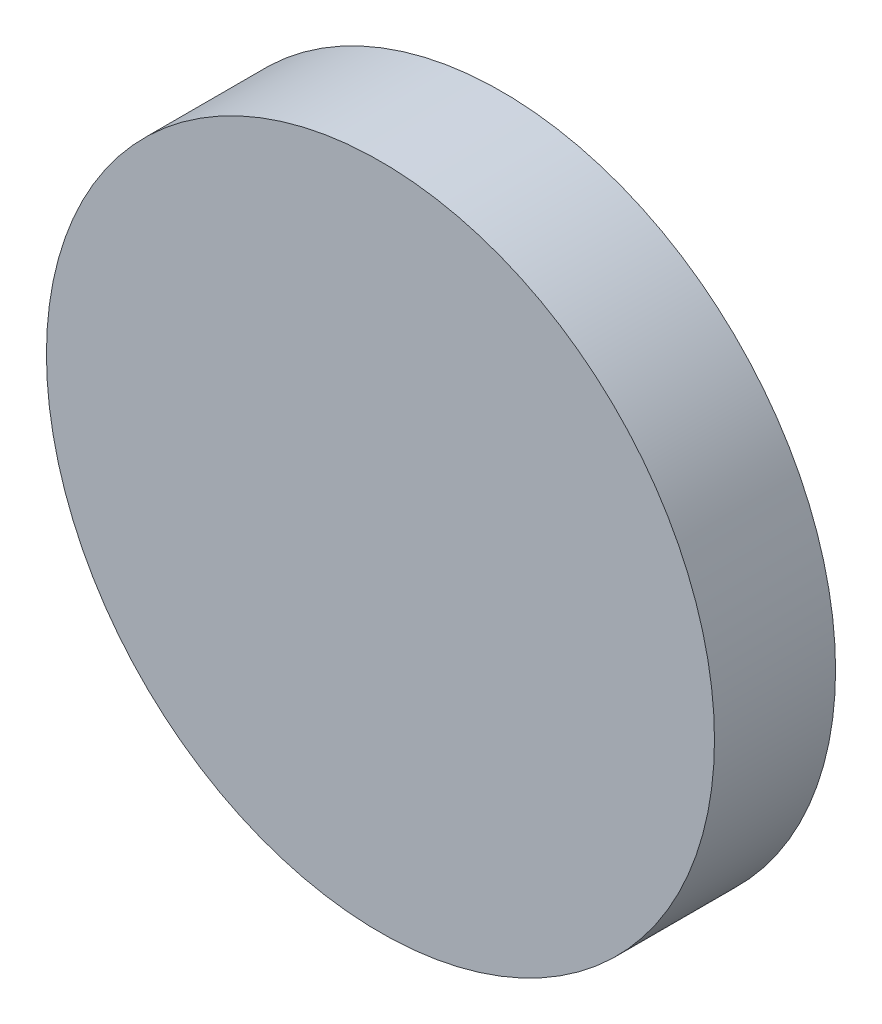
from build123d import *

# Parameters (mm, degrees)
SKETCH1_R           = 27.5857826
BOSS_EXTRUDE1_DEPTH = 10


with BuildPart() as part:
    # Sketch1 → Boss-Extrude1 (new body)
    with BuildSketch(Plane.XY):
        with Locations((-6.395390271, 2.928730124)):
            Circle(SKETCH1_R)
    extrude(amount=BOSS_EXTRUDE1_DEPTH)


solid = part.part
